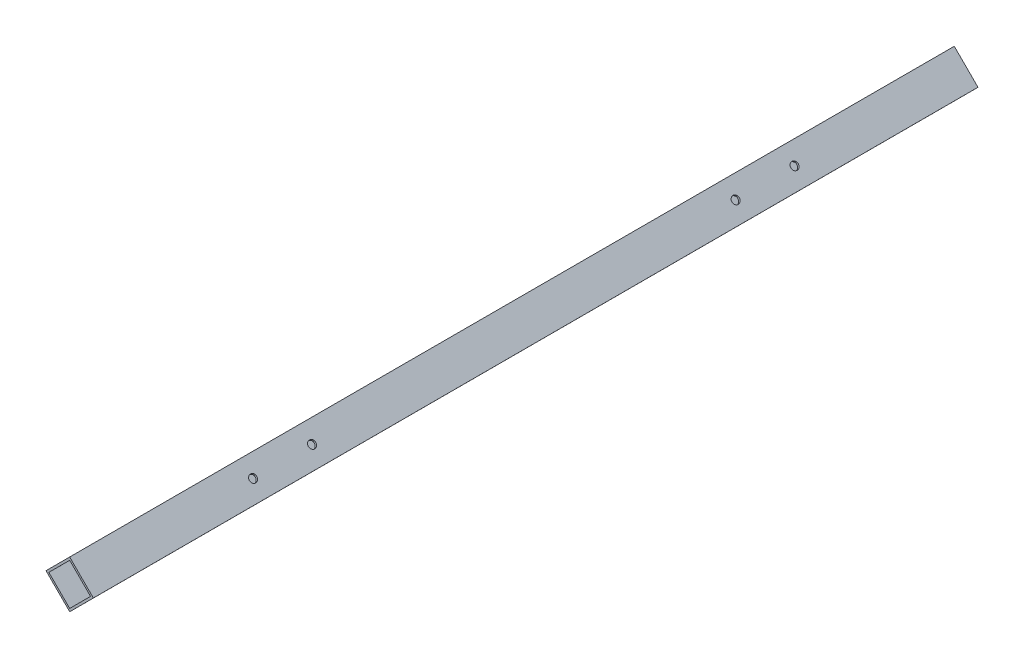
from build123d import *

# Parameters (mm, degrees)
EXTRUDE_1_DEPTH     = 660
SKETCH_2_R          = 2.75
CUT_EXTRUDE_1_DEPTH = 38.499979182


with BuildPart() as part:
    # 草圖1 → 填料-伸長1 (new body)
    with BuildSketch(Plane.XY):
        Polygon((0, 0), (17.69379362, -17.661530719), (0.032262901, -35.355324339), (-17.661530719, -17.69379362), align=None)
        Polygon((0.001935774, -2.12131946), (-15.540211259, -17.691857846), (0.030327127, -33.234004879), (15.57247416, -17.663466493), align=None, mode=Mode.SUBTRACT)
    extrude(amount=EXTRUDE_1_DEPTH)

    # 草圖2 → 除料-伸長1 (cut, through all)
    with BuildSketch(Plane(origin=(0, 0, 0), x_dir=(0.707751745, -0.706461229, 0), z_dir=(0.706461229, 0.707751745, 0))):
        with Locations((12.5, -488)):
            Circle(SKETCH_2_R)
        with Locations((12.5, -532)):
            Circle(SKETCH_2_R)
        with Locations((12.5, -128)):
            Circle(SKETCH_2_R)
        with Locations((12.5, -172)):
            Circle(SKETCH_2_R)
    extrude(amount=-CUT_EXTRUDE_1_DEPTH, mode=Mode.SUBTRACT)


solid = part.part
